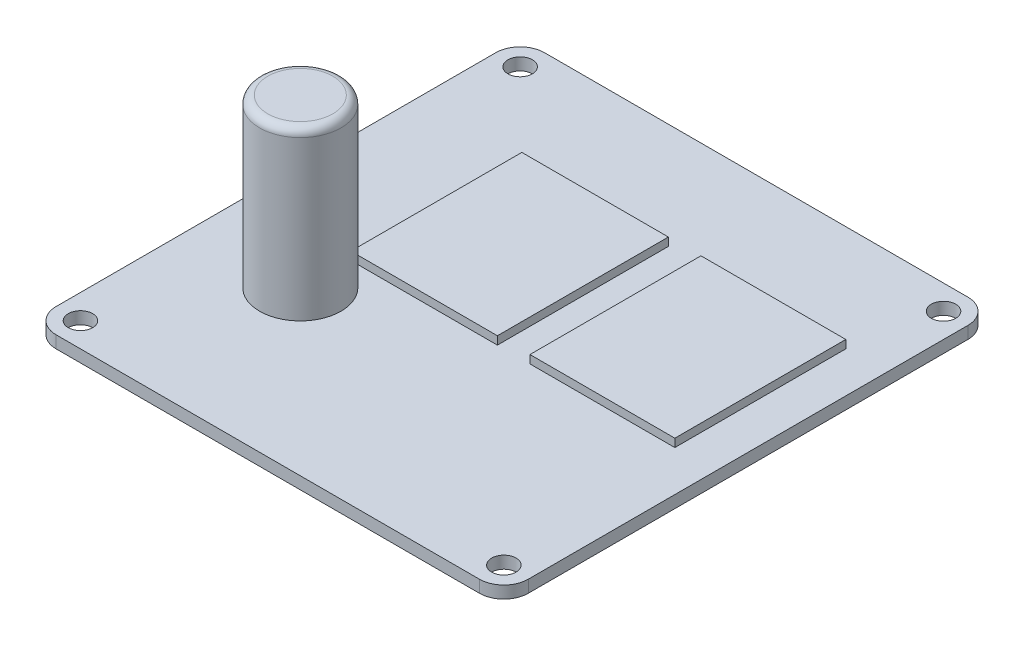
from build123d import *

# Parameters (mm, degrees)
BOSS_EXTRUDE2_DEPTH = 1.5
SKETCH3_W           = 17.792742237
SKETCH3_H           = 21
SKETCH3_W_2         = 18
BOSS_EXTRUDE4_DEPTH = 1
SKETCH5_R           = 5
BOSS_EXTRUDE6_DEPTH = 20.5
FILLET4_R           = 1
CUT_EXTRUDE1_REACH  = 3.5
SKETCH6_R           = 1.5


with BuildPart() as part:
    # Sketch1 → Boss-Extrude2 (new body)
    with BuildSketch(Plane(origin=(0, 0, 0), x_dir=(1, 0, 0), z_dir=(0, 1, 0))):
        with BuildLine():
            Line((-26, 30), (26, 30))
            ThreePointArc((26, 30), (28.121320344, 29.121320344), (29, 27))
            Line((29, 27), (29, -27))
            ThreePointArc((29, -27), (28.121320344, -29.121320344), (26, -30))
            Line((26, -30), (-26, -30))
            ThreePointArc((-26, -30), (-28.121320344, -29.121320344), (-29, -27))
            Line((-29, -27), (-29, 27))
            ThreePointArc((-29, 27), (-28.121320344, 29.121320344), (-26, 30))
        make_face()
    extrude(amount=-BOSS_EXTRUDE2_DEPTH)

    # Sketch3 → Boss-Extrude4 (add)
    with BuildSketch(Plane(origin=(0, 0, 0), x_dir=(1, 0, 0), z_dir=(0, 1, 0))):
        with Locations((15.103628882, 6.5)):
            Rectangle(SKETCH3_W, SKETCH3_H)
        with Locations((-6.792742237, 6.5)):
            Rectangle(SKETCH3_W_2, SKETCH3_H)
    extrude(amount=BOSS_EXTRUDE4_DEPTH)

    # Sketch5 → Boss-Extrude6 (add)
    with BuildSketch(Plane(origin=(0, 0, 0), x_dir=(1, 0, 0), z_dir=(0, 1, 0))):
        with Locations((-16, -10)):
            Circle(SKETCH5_R)
    extrude(amount=BOSS_EXTRUDE6_DEPTH)

    # Fillet4
    fillet4_edges = [part.edges().sort_by_distance(p)[0] for p in [
        (-21, 20.5, 10),
    ]]
    fillet(fillet4_edges, radius=FILLET4_R)

    # Sketch6 → Cut-Extrude1 (cut, up to next)
    with BuildSketch(Plane(origin=(0, 0, 0), x_dir=(1, 0, 0), z_dir=(0, 1, 0)), mode=Mode.PRIVATE) as cut_extrude1_sk1:
        with Locations((-26, 27)):
            Circle(SKETCH6_R)
    cut_extrude1_tool1 = extrude(cut_extrude1_sk1.sketch, amount=-CUT_EXTRUDE1_REACH, mode=Mode.PRIVATE) & part.part
    add(cut_extrude1_tool1.solids().sort_by_distance((-26, 0, -27))[0], mode=Mode.SUBTRACT)
    # Sketch6 → Cut-Extrude1 (cut, up to next)
    with BuildSketch(Plane(origin=(0, 0, 0), x_dir=(1, 0, 0), z_dir=(0, 1, 0)), mode=Mode.PRIVATE) as cut_extrude1_sk2:
        with Locations((26, 27)):
            Circle(SKETCH6_R)
    cut_extrude1_tool2 = extrude(cut_extrude1_sk2.sketch, amount=-CUT_EXTRUDE1_REACH, mode=Mode.PRIVATE) & part.part
    add(cut_extrude1_tool2.solids().sort_by_distance((26, 0, -27))[0], mode=Mode.SUBTRACT)
    # Sketch6 → Cut-Extrude1 (cut, up to next)
    with BuildSketch(Plane(origin=(0, 0, 0), x_dir=(1, 0, 0), z_dir=(0, 1, 0)), mode=Mode.PRIVATE) as cut_extrude1_sk3:
        with Locations((-26, -27)):
            Circle(SKETCH6_R)
    cut_extrude1_tool3 = extrude(cut_extrude1_sk3.sketch, amount=-CUT_EXTRUDE1_REACH, mode=Mode.PRIVATE) & part.part
    add(cut_extrude1_tool3.solids().sort_by_distance((-26, 0, 27))[0], mode=Mode.SUBTRACT)
    # Sketch6 → Cut-Extrude1 (cut, up to next)
    with BuildSketch(Plane(origin=(0, 0, 0), x_dir=(1, 0, 0), z_dir=(0, 1, 0)), mode=Mode.PRIVATE) as cut_extrude1_sk4:
        with Locations((26, -27)):
            Circle(SKETCH6_R)
    cut_extrude1_tool4 = extrude(cut_extrude1_sk4.sketch, amount=-CUT_EXTRUDE1_REACH, mode=Mode.PRIVATE) & part.part
    add(cut_extrude1_tool4.solids().sort_by_distance((26, 0, 27))[0], mode=Mode.SUBTRACT)


solid = part.part
